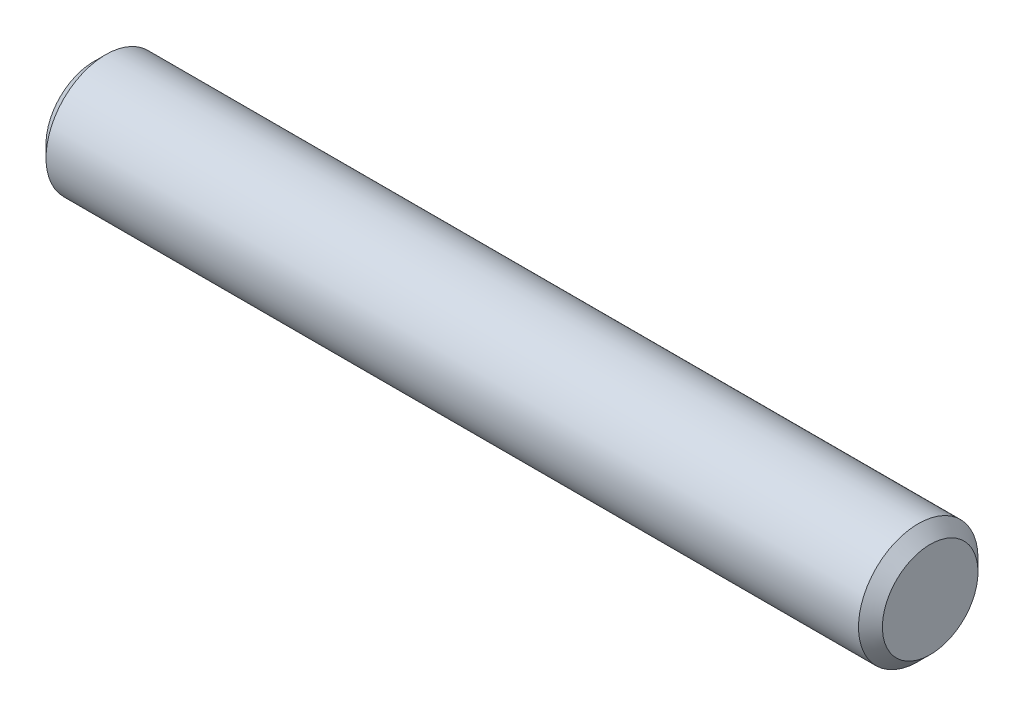
from build123d import *

# Parameters (mm, degrees)
SKETCH2_R           = 3.175
EXTRUDE1_DEPTH      = 22.225
EXTRUDE1_DEPTH_BACK = 22.225
CHAMFER1_SIZE       = 0.635


with BuildPart() as part:
    # Sketch2 → Extrude1 (new body, two sides)
    with BuildSketch(Plane(origin=(0, 0, 0), x_dir=(0, 0, -1), z_dir=(1, 0, 0))) as extrude1_sk:
        Circle(SKETCH2_R)
    extrude(amount=EXTRUDE1_DEPTH)
    extrude(extrude1_sk.sketch, amount=-EXTRUDE1_DEPTH_BACK)

    # Chamfer1
    chamfer1_edges = [part.edges().sort_by_distance(p)[0] for p in [
        (-22.225, 0, 3.175),
        (22.225, 0, 3.175),
    ]]
    chamfer(chamfer1_edges, length=CHAMFER1_SIZE)


solid = part.part
